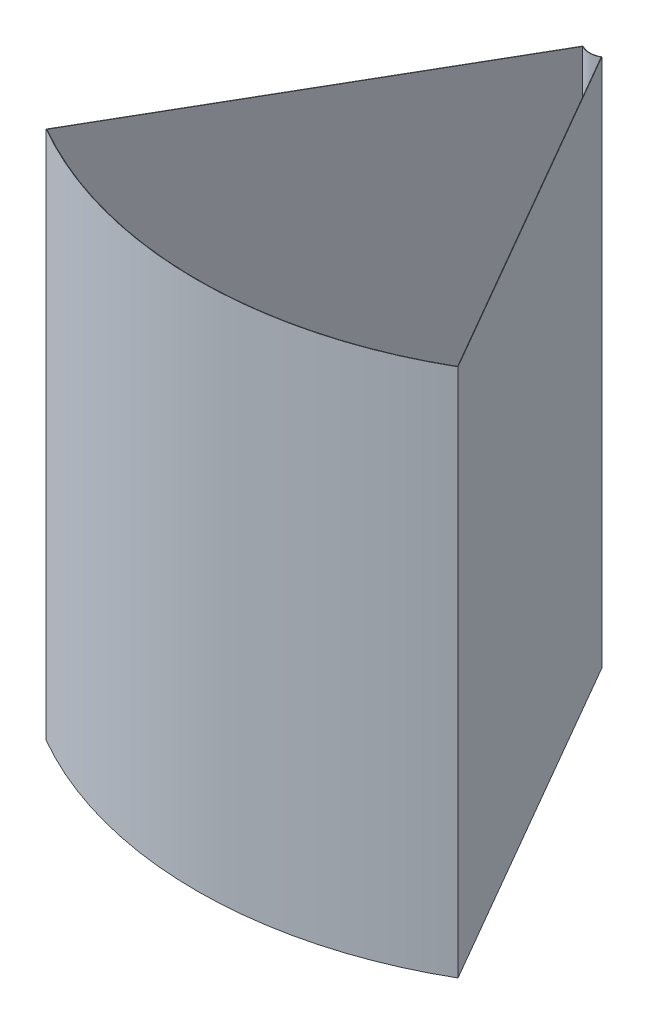
from build123d import *

# Parameters (mm, degrees)
BOSS_EXTRUDE1_DEPTH = 450
SHELL1_T            = -0.35


with BuildPart() as part:
    # Sketch1 → Boss-Extrude1 (new body)
    with BuildSketch(Plane(origin=(0, 0, 0), x_dir=(1, 0, 0), z_dir=(0, 1, 0))):
        with BuildLine():
            Line((-8, -13.856406461), (-175.0875, -303.26044577))
            ThreePointArc((-175.0875, -303.26044577), (0, -350.175), (175.0875, -303.26044577))
            Line((175.0875, -303.26044577), (8, -13.856406461))
            ThreePointArc((8, -13.856406461), (0, -16), (-8, -13.856406461))
        make_face()
    extrude(amount=BOSS_EXTRUDE1_DEPTH)

    # Shell1
    shell1_openings = [part.faces().sort_by_distance(p)[0] for p in [
        (0, 450, 170.822963058),
    ]]
    offset(amount=SHELL1_T, openings=shell1_openings, kind=Kind.INTERSECTION)


solid = part.part
